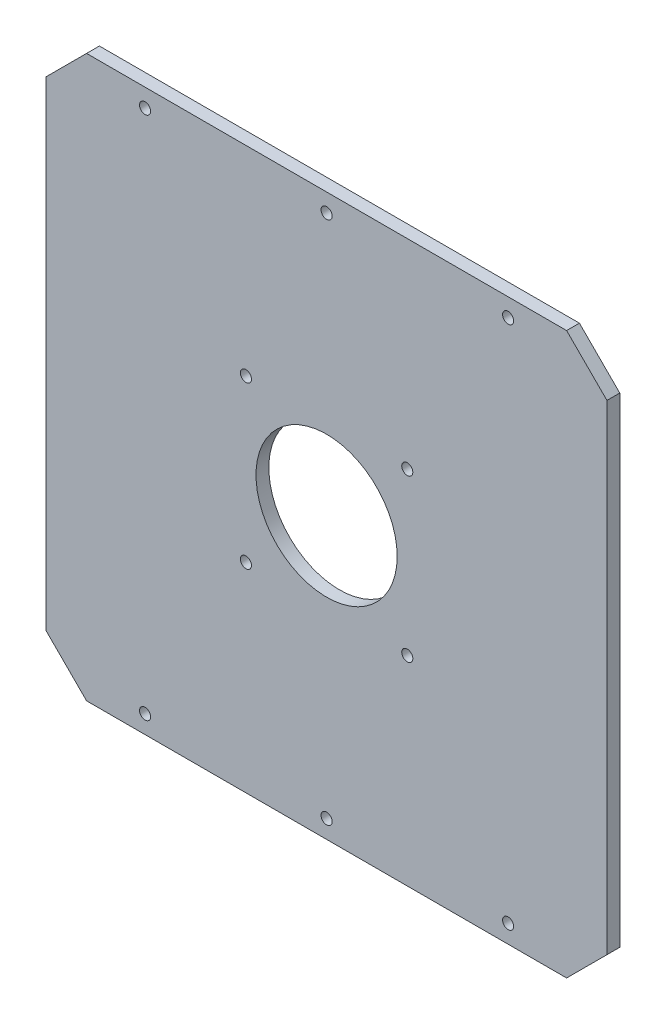
from build123d import *

# Parameters (mm, degrees)
SKETCH1_W           = 278
SKETCH1_H           = 278
BOSS_EXTRUDE1_DEPTH = 6.35
SKETCH2_R           = 35
SKETCH2_R_2         = 2.75
CUT_EXTRUDE1_DEPTH  = 7.35
CHAMFER1_SIZE       = 20
SKETCH4_R           = 2.75
CUT_EXTRUDE2_DEPTH  = 76.2


with BuildPart() as part:
    # Sketch1 → Boss-Extrude1 (new body)
    with BuildSketch(Plane.XY):
        Rectangle(SKETCH1_W, SKETCH1_H)
    extrude(amount=BOSS_EXTRUDE1_DEPTH)

    # Sketch2 → Cut-Extrude1 (cut, through all)
    with BuildSketch(Plane.XY.offset(6.35)):
        Circle(SKETCH2_R)
        with Locations((-40, 40)):
            Circle(SKETCH2_R_2)
        with Locations((40, 40)):
            Circle(SKETCH2_R_2)
        with Locations((40, -40)):
            Circle(SKETCH2_R_2)
        with Locations((-40, -40)):
            Circle(SKETCH2_R_2)
    extrude(amount=-CUT_EXTRUDE1_DEPTH, mode=Mode.SUBTRACT)

    # Chamfer1
    chamfer1_edges = [part.edges().sort_by_distance(p)[0] for p in [
        (-139, 139, 3.175),
        (139, 139, 3.175),
        (139, -139, 3.175),
        (-139, -139, 3.175),
    ]]
    chamfer(chamfer1_edges, length=CHAMFER1_SIZE)

    # Sketch4 → Cut-Extrude2 (cut)
    with BuildSketch(Plane.XY.offset(6.35)):
        with Locations((-90, 130)):
            Circle(SKETCH4_R)
        with Locations((0, 130)):
            Circle(SKETCH4_R)
        with Locations((90, 130)):
            Circle(SKETCH4_R)
        with Locations((90, -130)):
            Circle(SKETCH4_R)
        with Locations((0, -130)):
            Circle(SKETCH4_R)
        with Locations((-90, -130)):
            Circle(SKETCH4_R)
    extrude(amount=-CUT_EXTRUDE2_DEPTH, mode=Mode.SUBTRACT)


solid = part.part
